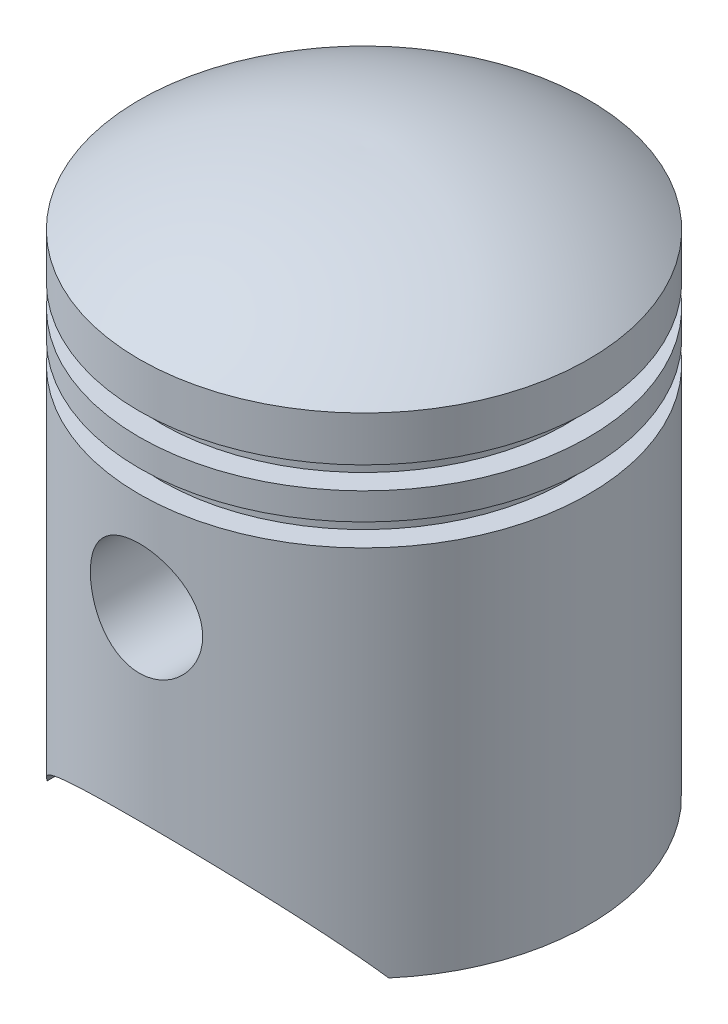
from build123d import *

# Parameters (mm, degrees)
SKETCH3_R               = 6.25
CUT_EXTRUDE1_DEPTH      = 26.0000001
CUT_EXTRUDE1_DEPTH_BACK = 26.0000001
BOSS_EXTRUDE3_START     = 12
SKETCH4_R               = 7.25
SKETCH4_R_2             = 6.25
BOSS_EXTRUDE3_DEPTH     = 11.925679


with BuildPart() as part:
    # Sketch2 → Revolve1 (revolve)
    with BuildSketch(Plane.XY):
        with BuildLine():
            Line((25, 0), (25, 41.5))
            Line((25, 41.5), (22.5, 41.5))
            Line((22.5, 41.5), (22.5, 44))
            Line((22.5, 44), (25, 44))
            Line((25, 44), (25, 47))
            Line((25, 47), (22.5, 47))
            Line((22.5, 47), (22.5, 49.5))
            Line((22.5, 49.5), (25, 49.5))
            Line((25, 49.5), (25, 54.5))
            ThreePointArc((25, 54.5), (13.174901691, 60.609067785), (0, 62.5))
            Line((0, 62.5), (0, 60.49936285))
            ThreePointArc((0, 60.49936285), (12.069492637, 58.859165445), (23, 53.484511145))
            Line((23, 53.484511145), (23, 51.5))
            Line((23, 51.5), (20.5, 51.5))
            Line((20.5, 51.5), (20.5, 45.5))
            Line((20.5, 45.5), (20.5, 39.5))
            Line((20.5, 39.5), (23, 39.5))
            Line((23, 39.5), (23, 0))
            Line((23, 0), (25, 0))
        make_face()
    revolve(axis=Axis((0, 62.5, 0), (0, -1, 0)))

    # Sketch3 → Cut-Extrude1 (cut, two sides)
    with BuildSketch(Plane.XY) as cut_extrude1_sk:
        with Locations((0, 30.5)):
            Circle(SKETCH3_R)
        with BuildLine():
            Line((-19, 0), (19, 0))
            ThreePointArc((19, 0), (0, 10), (-19, 0))
        make_face()
    extrude(amount=CUT_EXTRUDE1_DEPTH, mode=Mode.SUBTRACT)
    extrude(cut_extrude1_sk.sketch, amount=-CUT_EXTRUDE1_DEPTH_BACK, mode=Mode.SUBTRACT)

    # Sketch4 → Boss-Extrude3 (add)
    with BuildSketch(Plane.XY.offset(BOSS_EXTRUDE3_START)):
        with Locations((0, 30.5)):
            Circle(SKETCH4_R)
        with Locations((0, 30.5)):
            Circle(SKETCH4_R_2, mode=Mode.SUBTRACT)
    boss_extrude3 = extrude(amount=BOSS_EXTRUDE3_DEPTH)

    # Mirror2: Boss-Extrude3 across plane
    add(boss_extrude3.mirror(Plane.XY))


solid = part.part
